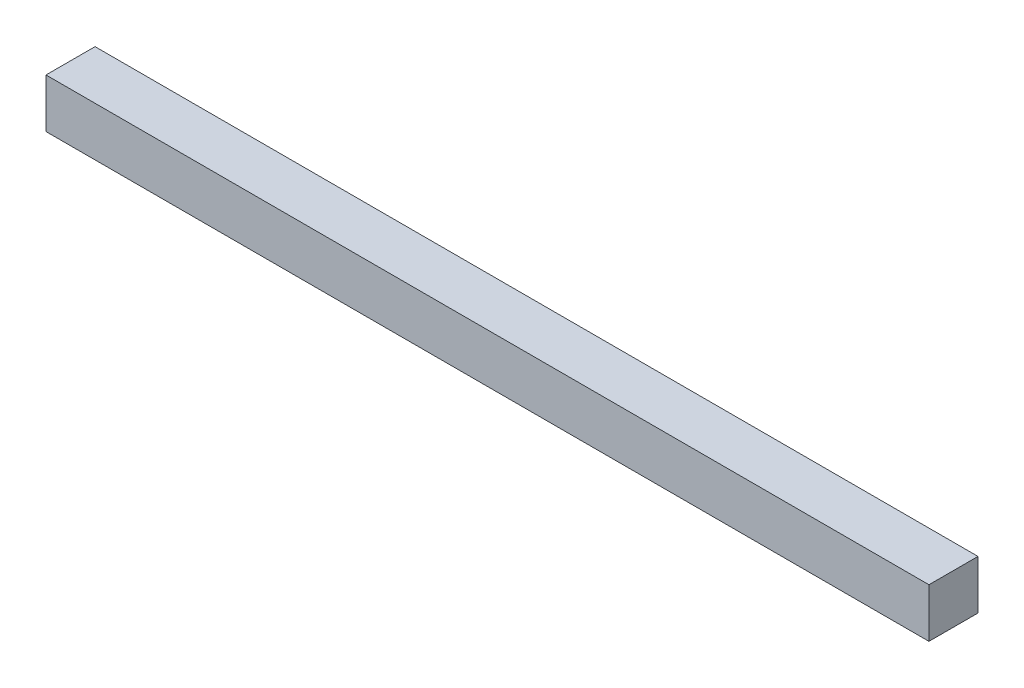
from build123d import *

# Parameters (mm, degrees)
SKETCH2_W           = 6.35
SKETCH2_H           = 6.35
BOSS_EXTRUDE1_DEPTH = 57.15


with BuildPart() as part:
    # Sketch2 → Boss-Extrude1 (new body, symmetric)
    with BuildSketch(Plane(origin=(0, 0, 0), x_dir=(0, 0, -1), z_dir=(1, 0, 0))):
        Rectangle(SKETCH2_W, SKETCH2_H)
    extrude(amount=BOSS_EXTRUDE1_DEPTH, both=True)


solid = part.part
